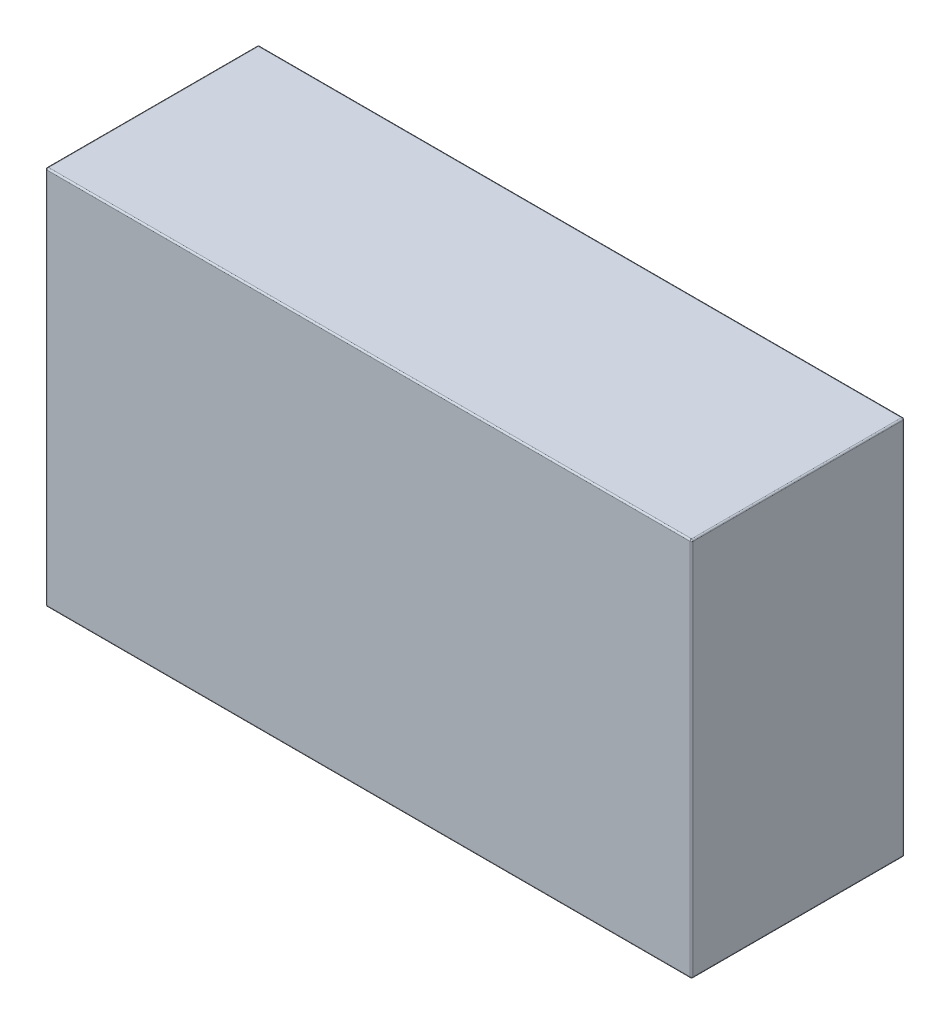
from build123d import *

# Parameters (mm, degrees)
SKETCH1_W           = 107.95
SKETCH1_H           = 63.5
BOSS_EXTRUDE1_DEPTH = 17.78
FILLET1_R           = 0.254


with BuildPart() as part:
    # Sketch1 → Boss-Extrude1 (new body, symmetric)
    with BuildSketch(Plane.XY):
        Rectangle(SKETCH1_W, SKETCH1_H)
    extrude(amount=BOSS_EXTRUDE1_DEPTH, both=True)

    # Fillet1
    fillet1_edges = [part.edges().sort_by_distance(p)[0] for p in [
        (-53.975, 0, 17.78),
        (0, -31.75, 17.78),
        (53.975, 0, 17.78),
        (0, -31.75, -17.78),
        (-53.975, 0, -17.78),
        (0, 31.75, -17.78),
        (53.975, 0, -17.78),
        (53.975, -31.75, 0),
        (-53.975, -31.75, 0),
        (-53.975, 31.75, 0),
        (53.975, 31.75, 0),
        (0, 31.75, 17.78),
    ]]
    fillet(fillet1_edges, radius=FILLET1_R)


solid = part.part
